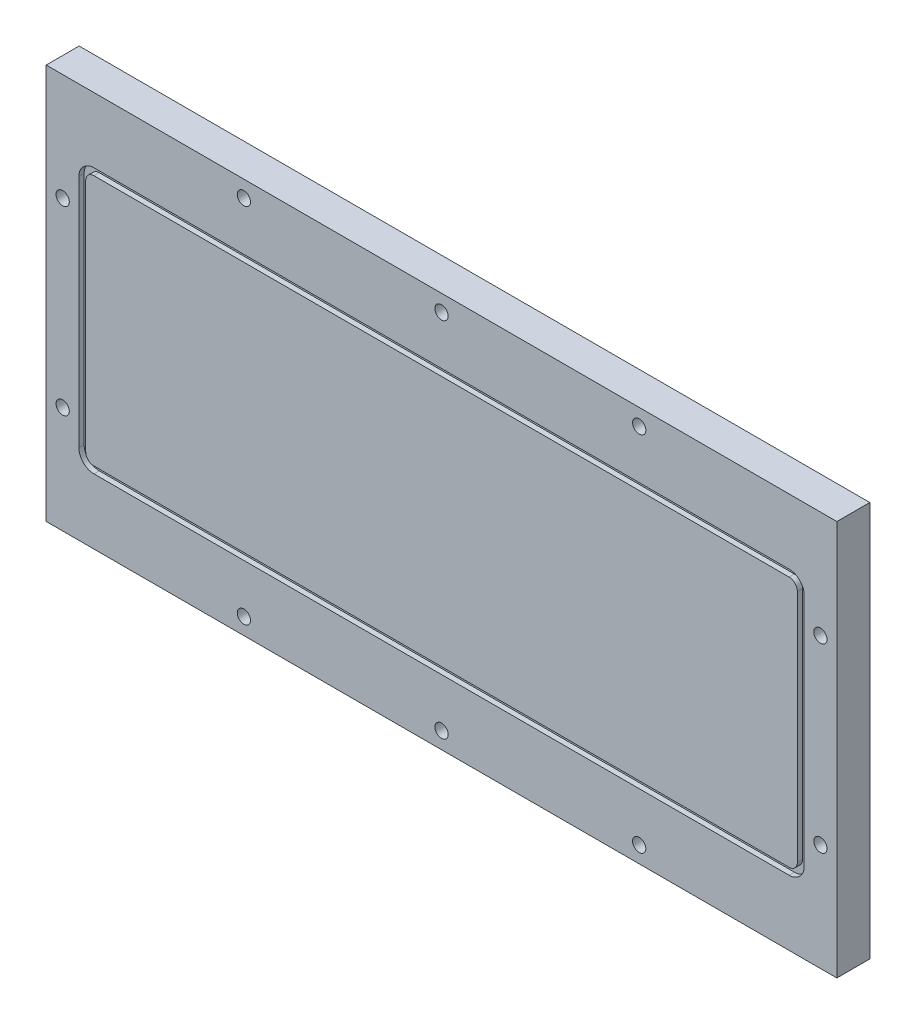
from build123d import *

# Parameters (mm, degrees)
SKETCH1_W                                       = 304.8
SKETCH1_H                                       = 152.4
BOSS_EXTRUDE1_DEPTH                             = 12.7
SKETCH2_W                                       = 279.6032
SKETCH2_H                                       = 102.1842
CUT_EXTRUDE1_DEPTH                              = 2.032
SKETCH3_W                                       = 274.32
SKETCH3_H                                       = 96.901
BOSS_EXTRUDE2_DEPTH                             = 2.032
F_1_4_20_TAPPED_HOLE1_D                         = 5.1054
F_1_4_20_TAPPED_HOLE1_DEPTH                     = 7.62
F_1_4_20_TAPPED_HOLE1_TIP                       = 1.533816902
F_6_32_TAPPED_HOLE1_D                           = 2.7051
F_6_32_TAPPED_HOLE1_DEPTH                       = 9.38784
F_6_32_TAPPED_HOLE1_TIP                         = 0.81269403
CBORE_FOR_10_SOCKET_HEAD_CAP_SCREW1_D           = 5.1054
CBORE_FOR_10_SOCKET_HEAD_CAP_SCREW1_CBORE_D     = 9.525
CBORE_FOR_10_SOCKET_HEAD_CAP_SCREW1_CBORE_DEPTH = 4.826
FILLET1_R                                       = 3.175
FILLET2_R                                       = 5.8166
MIRROR2_COPY_1_D                                = 5.1054
MIRROR2_COPY_1_CBORE_D                          = 9.525
MIRROR2_COPY_1_CBORE_DEPTH                      = 4.826


with BuildPart() as part:
    # Sketch1 → Boss-Extrude1 (new body)
    with BuildSketch(Plane.XY.offset(12.7)):
        Rectangle(SKETCH1_W, SKETCH1_H)
    extrude(amount=-BOSS_EXTRUDE1_DEPTH)

    # Sketch2 → Cut-Extrude1 (cut)
    with BuildSketch(Plane.XY.offset(12.7)):
        Rectangle(SKETCH2_W, SKETCH2_H)
    extrude(amount=-CUT_EXTRUDE1_DEPTH, mode=Mode.SUBTRACT)

    # Sketch3 → Boss-Extrude2 (add)
    with BuildSketch(Plane.XY.offset(10.668)):
        Rectangle(SKETCH3_W, SKETCH3_H)
    extrude(amount=BOSS_EXTRUDE2_DEPTH)

    # 1/4-20 Tapped Hole1
    with Locations(Plane(origin=(0, 0, 0), x_dir=(-1, 0, 0), z_dir=(0, 0, -1))):
        with Locations((120.65, -38.1), (-120.65, 38.1), (120.65, 38.1), (-120.65, -38.1)):
            Hole(F_1_4_20_TAPPED_HOLE1_D / 2, depth=F_1_4_20_TAPPED_HOLE1_DEPTH)
            with Locations((0, 0, -(F_1_4_20_TAPPED_HOLE1_DEPTH + F_1_4_20_TAPPED_HOLE1_TIP / 2))):  # 118° drill point
                Cone(0, F_1_4_20_TAPPED_HOLE1_D / 2, F_1_4_20_TAPPED_HOLE1_TIP, mode=Mode.SUBTRACT)

    # #6-32 Tapped Hole1
    with Locations(Plane(origin=(0, 0, 0), x_dir=(-1, 0, 0), z_dir=(0, 0, -1))):
        with Locations((0, 12.7)):
            Hole(F_6_32_TAPPED_HOLE1_D / 2, depth=F_6_32_TAPPED_HOLE1_DEPTH)
            with Locations((0, 0, -(F_6_32_TAPPED_HOLE1_DEPTH + F_6_32_TAPPED_HOLE1_TIP / 2))):  # 118° drill point
                Cone(0, F_6_32_TAPPED_HOLE1_D / 2, F_6_32_TAPPED_HOLE1_TIP, mode=Mode.SUBTRACT)

    # CBORE for #10 Socket Head Cap Screw1 (through all)
    with Locations(Plane(origin=(0, 0, 0), x_dir=(-1, 0, 0), z_dir=(0, 0, -1))):
        with Locations((146.05, 34.925), (0, 69.85), (76.2, 69.85)):
            cbore_for_10_socket_head_cap_screw1 = CounterBoreHole(CBORE_FOR_10_SOCKET_HEAD_CAP_SCREW1_D / 2, CBORE_FOR_10_SOCKET_HEAD_CAP_SCREW1_CBORE_D / 2, CBORE_FOR_10_SOCKET_HEAD_CAP_SCREW1_CBORE_DEPTH)

    # Fillet1
    fillet1_edges = [part.edges().sort_by_distance(p)[0] for p in [
        (137.16, 48.4505, 11.684),
        (-137.16, 48.4505, 11.684),
        (-137.16, -48.4505, 11.684),
        (137.16, -48.4505, 11.684),
    ]]
    fillet(fillet1_edges, radius=FILLET1_R)

    # Fillet2
    fillet2_edges = [part.edges().sort_by_distance(p)[0] for p in [
        (-139.8016, -51.0921, 11.684),
        (-139.8016, 51.0921, 11.684),
        (139.8016, 51.0921, 11.684),
        (139.8016, -51.0921, 11.684),
    ]]
    fillet(fillet2_edges, radius=FILLET2_R)

    # Mirror1: CBORE for #10 Socket Head Cap Screw1 across plane
    add(cbore_for_10_socket_head_cap_screw1.mirror(Plane(origin=(0, 0, 0), x_dir=(0, 0, 1), z_dir=(1, 0, 0))), mode=Mode.SUBTRACT)

    # Mirror2: CBORE for #10 Socket Head Cap Screw1 across plane
    add(cbore_for_10_socket_head_cap_screw1.mirror(Plane.ZX), mode=Mode.SUBTRACT)

    # Mirror2 copy 1 (through all)
    with Locations(Plane(origin=(0, 0, 0), x_dir=(1, 0, 0), z_dir=(0, 0, -1))):
        with Locations((146.05, 34.925), (0, 69.85), (76.2, 69.85)):
            CounterBoreHole(MIRROR2_COPY_1_D / 2, MIRROR2_COPY_1_CBORE_D / 2, MIRROR2_COPY_1_CBORE_DEPTH)


solid = part.part
